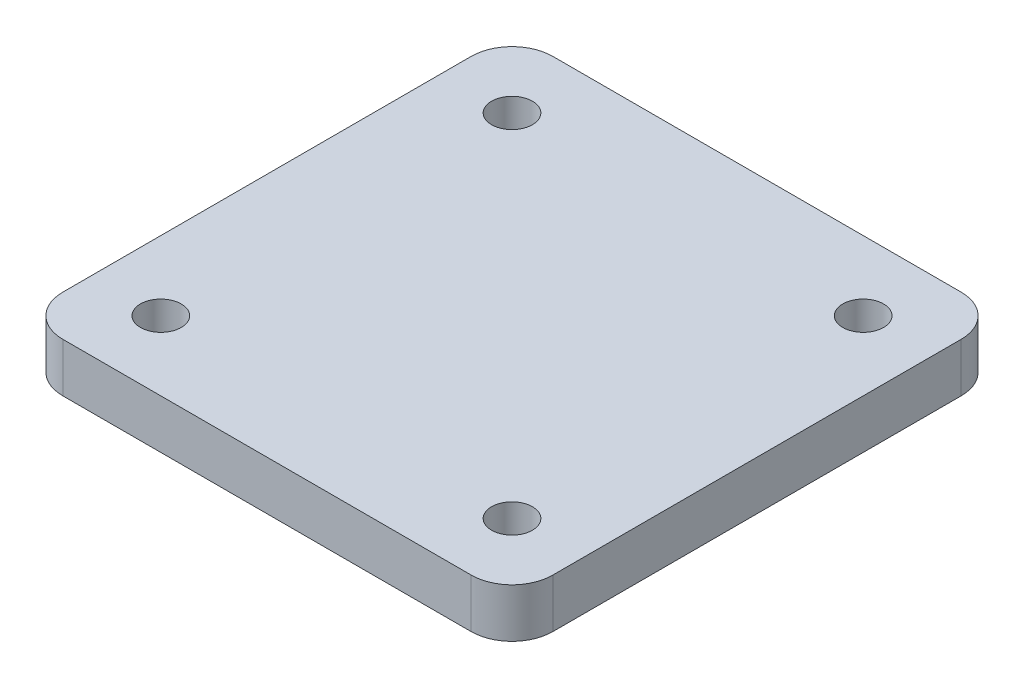
from build123d import *

# Parameters (mm, degrees)
SKETCH1_R           = 2.5
BOSS_EXTRUDE1_DEPTH = 6


with BuildPart() as part:
    # Sketch1 → Boss-Extrude1 (new body)
    with BuildSketch(Plane(origin=(0, 0, 0), x_dir=(1, 0, 0), z_dir=(0, 1, 0))):
        with BuildLine():
            Line((-5, 0), (-55, 0))
            ThreePointArc((-55, 0), (-58.535533906, 1.464466094), (-60, 5))
            Line((-60, 5), (-60, 55))
            ThreePointArc((-60, 55), (-58.535533906, 58.535533906), (-55, 60))
            Line((-55, 60), (-5, 60))
            ThreePointArc((-5, 60), (-1.464466094, 58.535533906), (0, 55))
            Line((0, 55), (0, 5))
            ThreePointArc((0, 5), (-1.464466094, 1.464466094), (-5, 0))
        make_face()
        with Locations((-51.5, 51.5)):
            Circle(SKETCH1_R, mode=Mode.SUBTRACT)
        with Locations((-8.5, 51.5)):
            Circle(SKETCH1_R, mode=Mode.SUBTRACT)
        with Locations((-8.5, 8.5)):
            Circle(SKETCH1_R, mode=Mode.SUBTRACT)
        with Locations((-51.5, 8.5)):
            Circle(SKETCH1_R, mode=Mode.SUBTRACT)
    extrude(amount=BOSS_EXTRUDE1_DEPTH)


solid = part.part
